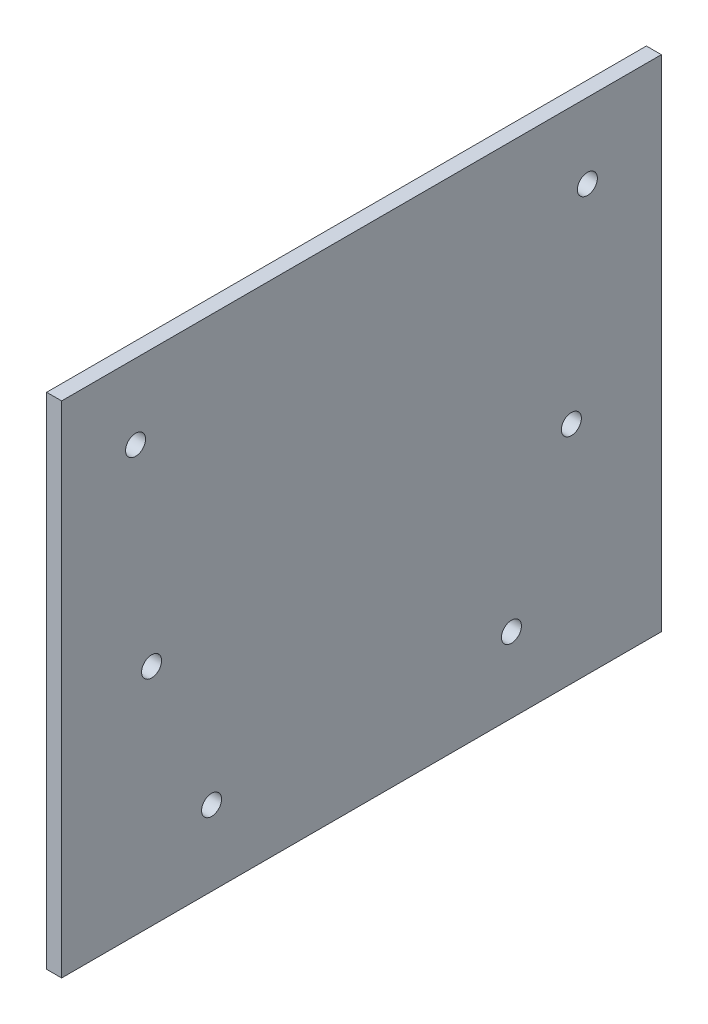
from build123d import *

# Parameters (mm, degrees)
SKETCH1_W           = 120
SKETCH1_H           = 100
BOSS_EXTRUDE1_DEPTH = 3
SKETCH2_R           = 2
CUT_EXTRUDE1_DEPTH  = 4
SKETCH3_R           = 2
CUT_EXTRUDE2_DEPTH  = 4
SKETCH4_R           = 2
CUT_EXTRUDE3_DEPTH  = 4


with BuildPart() as part:
    # Sketch1 → Boss-Extrude1 (new body)
    with BuildSketch(Plane(origin=(0, 0, 0), x_dir=(0, 0, -1), z_dir=(1, 0, 0))):
        with Locations((26.146465375, -0.01894847)):
            Rectangle(SKETCH1_W, SKETCH1_H)
    extrude(amount=BOSS_EXTRUDE1_DEPTH)

    # Sketch2 → Cut-Extrude1 (cut, through all)
    with BuildSketch(Plane(origin=(3, 0, 0), x_dir=(0, 0, -1), z_dir=(1, 0, 0))):
        with Locations((-3.853534625, -35.01894847)):
            Circle(SKETCH2_R)
        with Locations((56.146465375, -35.01894847)):
            Circle(SKETCH2_R)
    extrude(amount=-CUT_EXTRUDE1_DEPTH, mode=Mode.SUBTRACT)

    # Sketch3 → Cut-Extrude2 (cut, through all)
    with BuildSketch(Plane.ZY):
        with Locations((-68.146465375, -5.01894847)):
            Circle(SKETCH3_R)
        with Locations((15.853534625, -5.01894847)):
            Circle(SKETCH3_R)
    extrude(amount=-CUT_EXTRUDE2_DEPTH, mode=Mode.SUBTRACT)

    # Sketch4 → Cut-Extrude3 (cut, through all)
    with BuildSketch(Plane.ZY):
        with Locations((19.055575654, 34.98105153)):
            Circle(SKETCH4_R)
        with Locations((-71.348506404, 34.98105153)):
            Circle(SKETCH4_R)
    extrude(amount=-CUT_EXTRUDE3_DEPTH, mode=Mode.SUBTRACT)


solid = part.part
